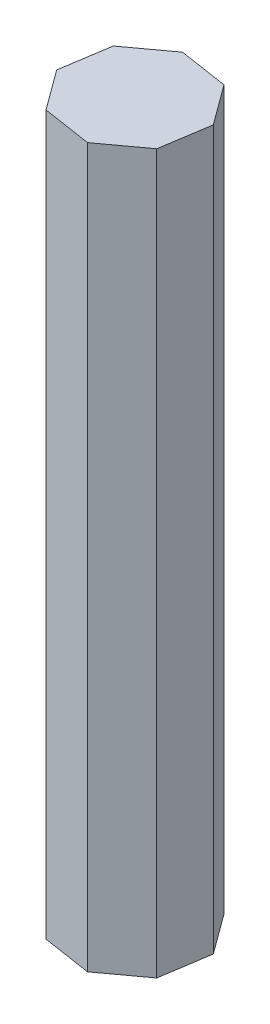
from build123d import *

# Parameters (mm, degrees)
BOSS_EXTRUDE1_DEPTH = 152.4


with BuildPart() as part:
    # Sketch1 → Boss-Extrude1 (new body)
    with BuildSketch(Plane(origin=(0, 0, 0), x_dir=(1, 0, 0), z_dir=(0, 1, 0))):
        Polygon((11.749260101, -7.135676291), (13.353666585, 3.262296397), (7.135676291, 11.749260101), (-3.262296397, 13.353666585), (-11.749260101, 7.135676291), (-13.353666585, -3.262296397), (-7.135676291, -11.749260101), (3.262296397, -13.353666585), align=None)
    extrude(amount=-BOSS_EXTRUDE1_DEPTH)


solid = part.part
